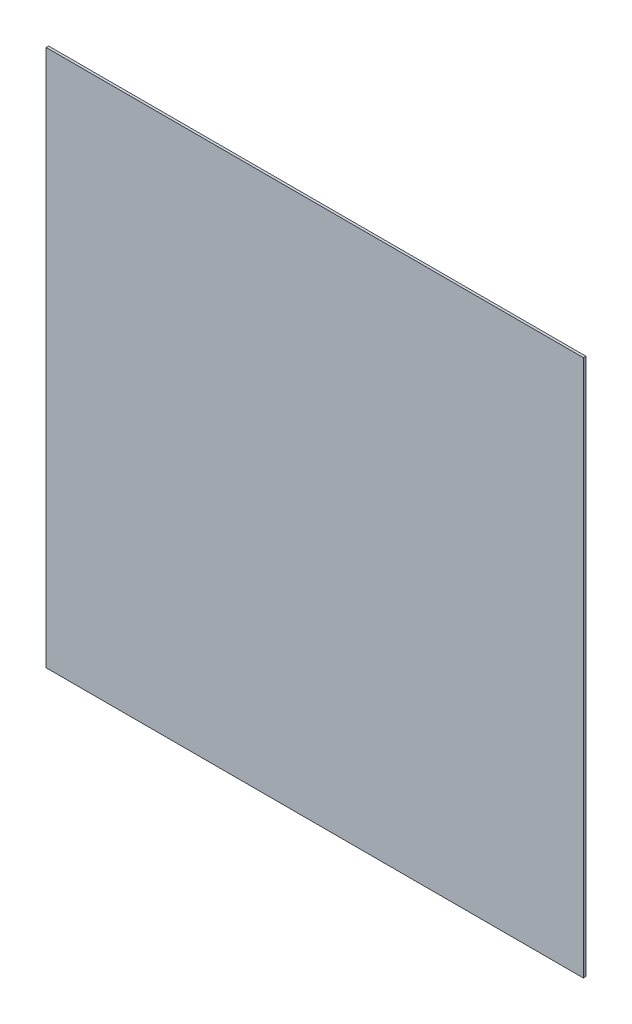
from build123d import *

# Parameters (mm, degrees)
ESQUISSE1_W        = 640
ESQUISSE1_H        = 640
BOSS_EXTRU_1_DEPTH = 3


with BuildPart() as part:
    # Esquisse1 → Boss.-Extru.1 (new body)
    with BuildSketch(Plane.XY):
        with Locations((-320, 320)):
            Rectangle(ESQUISSE1_W, ESQUISSE1_H)
    extrude(amount=BOSS_EXTRU_1_DEPTH)


solid = part.part
